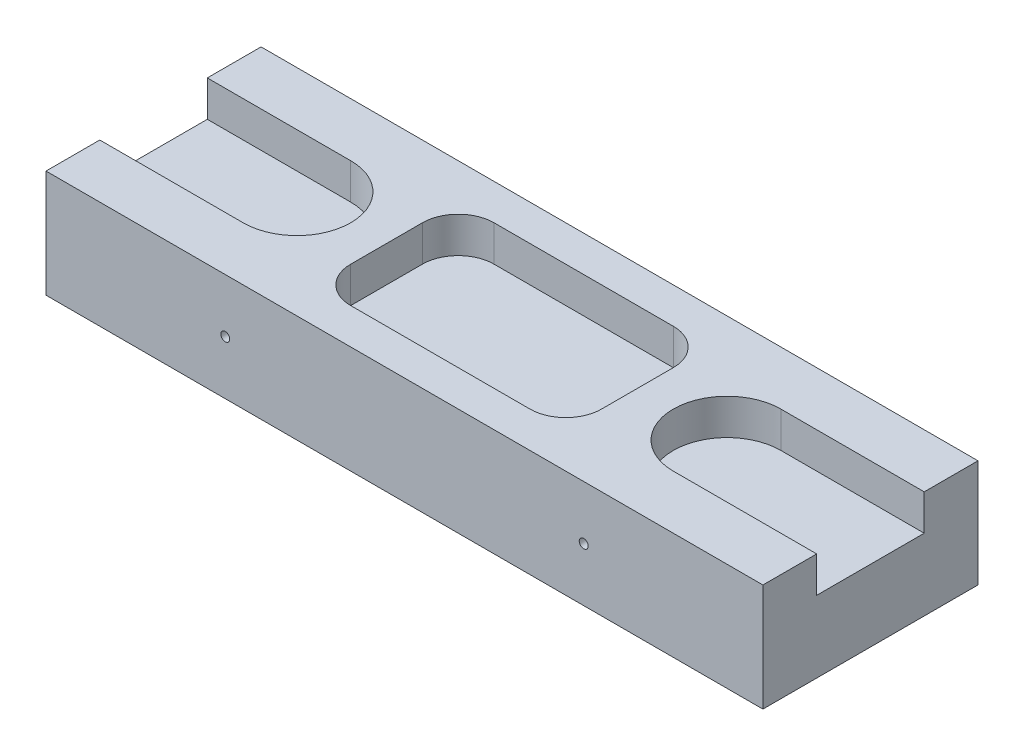
from build123d import *

# Parameters (mm, degrees)
SKETCH1_W           = 100
SKETCH1_H           = 30
BOSS_EXTRUDE1_DEPTH = 15
CUT_EXTRUDE1_DEPTH  = 5
SKETCH3_R           = 0.625
CUT_EXTRUDE2_DEPTH  = 30
CUT_EXTRUDE3_DEPTH  = 5


with BuildPart() as part:
    # Sketch1 → Boss-Extrude1 (new body)
    with BuildSketch(Plane(origin=(0, 0, 0), x_dir=(1, 0, 0), z_dir=(0, 1, 0))):
        with Locations((50, 15)):
            Rectangle(SKETCH1_W, SKETCH1_H)
    extrude(amount=BOSS_EXTRUDE1_DEPTH)

    # Sketch2 → Cut-Extrude1 (cut)
    with BuildSketch(Plane(origin=(0, 15, 0), x_dir=(1, 0, 0), z_dir=(0, 1, 0))):
        with BuildLine():
            Line((-20, 22.5), (20, 22.5))
            ThreePointArc((20, 22.5), (27.5, 15), (20, 7.5))
            Line((20, 7.5), (-20, 7.5))
            ThreePointArc((-20, 7.5), (-27.5, 15), (-20, 22.5))
        make_face()
        with BuildLine():
            Line((120, 22.5), (80, 22.5))
            ThreePointArc((80, 22.5), (72.5, 15), (80, 7.5))
            Line((80, 7.5), (120, 7.5))
            ThreePointArc((120, 7.5), (127.5, 15), (120, 22.5))
        make_face()
    extrude(amount=-CUT_EXTRUDE1_DEPTH, mode=Mode.SUBTRACT)

    # Sketch3 → Cut-Extrude2 (cut)
    with BuildSketch(Plane.XY):
        with Locations((25, 7.5)):
            Circle(SKETCH3_R)
        with Locations((75, 7.5)):
            Circle(SKETCH3_R)
    extrude(amount=-CUT_EXTRUDE2_DEPTH, mode=Mode.SUBTRACT)

    # Sketch4 → Cut-Extrude3 (cut)
    with BuildSketch(Plane(origin=(0, 15, 0), x_dir=(1, 0, 0), z_dir=(0, 1, 0))):
        with BuildLine():
            Line((37.5, 25), (62.5, 25))
            ThreePointArc((62.5, 25), (66.035533906, 23.535533906), (67.5, 20))
            Line((67.5, 20), (67.5, 10))
            ThreePointArc((67.5, 10), (66.035533906, 6.464466094), (62.5, 5))
            Line((62.5, 5), (37.5, 5))
            ThreePointArc((37.5, 5), (33.964466094, 6.464466094), (32.5, 10))
            Line((32.5, 10), (32.5, 20))
            ThreePointArc((32.5, 20), (33.964466094, 23.535533906), (37.5, 25))
        make_face()
    extrude(amount=-CUT_EXTRUDE3_DEPTH, mode=Mode.SUBTRACT)


solid = part.part
